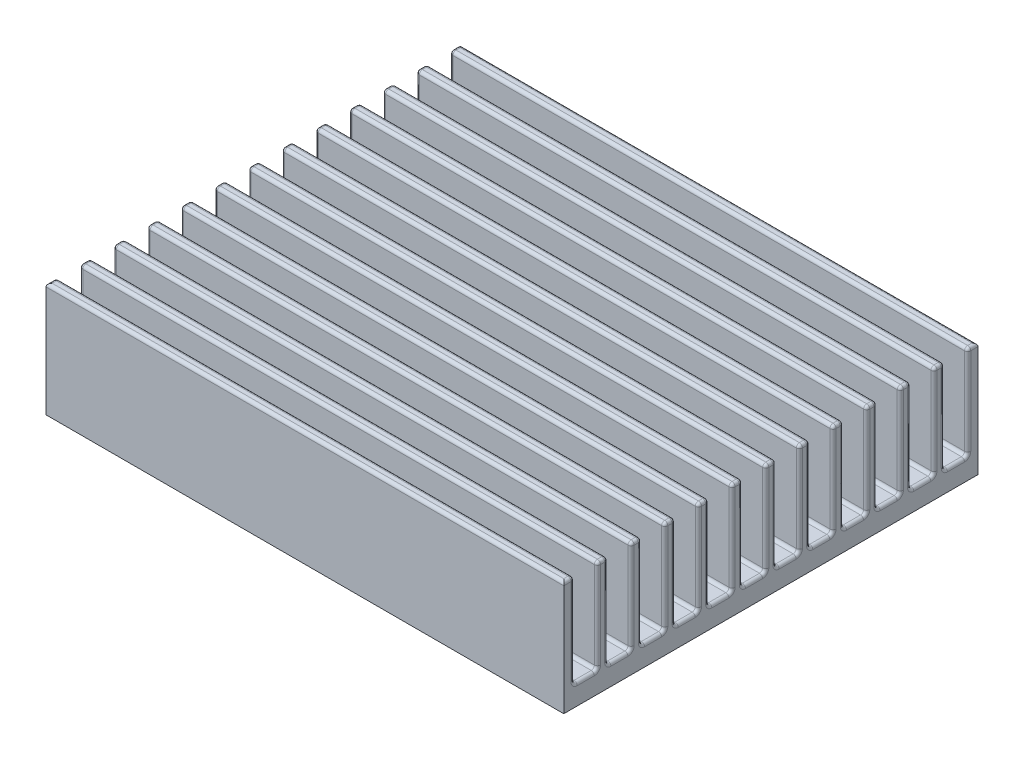
from build123d import *

# Parameters (mm, degrees)
SKETCH1_W           = 50
SKETCH1_H           = 40
BOSS_EXTRUDE1_DEPTH = 2
SKETCH2_W           = 1
SKETCH2_H           = 9
BOSS_EXTRUDE2_DEPTH = 50
FILLET1_R           = 0.3
SKETCH3_R           = 1.5
CUT_EXTRUDE1_DEPTH  = 2


with BuildPart() as part:
    # Sketch1 → Boss-Extrude1 (new body)
    with BuildSketch(Plane(origin=(0, 0, 0), x_dir=(1, 0, 0), z_dir=(0, 1, 0))):
        Rectangle(SKETCH1_W, SKETCH1_H)
    extrude(amount=BOSS_EXTRUDE1_DEPTH)

    # Sketch2 → Boss-Extrude2 (add)
    with BuildSketch(Plane(origin=(25, 0, 0), x_dir=(0, 0, -1), z_dir=(1, 0, 0))):
        with Locations((-19.5, 6.5)):
            Rectangle(SKETCH2_W, SKETCH2_H)
        with Locations((-16.25, 6.5)):
            Rectangle(SKETCH2_W, SKETCH2_H)
        with Locations((-13, 6.5)):
            Rectangle(SKETCH2_W, SKETCH2_H)
        with Locations((-9.75, 6.5)):
            Rectangle(SKETCH2_W, SKETCH2_H)
        with Locations((-6.5, 6.5)):
            Rectangle(SKETCH2_W, SKETCH2_H)
        with Locations((-3.25, 6.5)):
            Rectangle(SKETCH2_W, SKETCH2_H)
        with Locations((0, 6.5)):
            Rectangle(SKETCH2_W, SKETCH2_H)
        with Locations((3.25, 6.5)):
            Rectangle(SKETCH2_W, SKETCH2_H)
        with Locations((6.5, 6.5)):
            Rectangle(SKETCH2_W, SKETCH2_H)
        with Locations((9.75, 6.5)):
            Rectangle(SKETCH2_W, SKETCH2_H)
        with Locations((13, 6.5)):
            Rectangle(SKETCH2_W, SKETCH2_H)
        with Locations((16.25, 6.5)):
            Rectangle(SKETCH2_W, SKETCH2_H)
        with Locations((19.5, 6.5)):
            Rectangle(SKETCH2_W, SKETCH2_H)
    extrude(amount=-BOSS_EXTRUDE2_DEPTH)

    # Fillet1
    fillet1_edges = [part.edges().sort_by_distance(p)[0] for p in [
        (0, 11, -6),
        (0, 11, -7),
        (0, 2, -7),
        (0, 2, -6),
        (25, 11, -6.5),
        (25, 6.5, -6),
        (25, 6.5, -7),
        (-25, 11, -6.5),
        (-25, 6.5, -7),
        (-25, 6.5, -6),
        (-25, 2, -8.125),
        (25, 2, -11.375),
        (0, 11, -9.25),
        (0, 11, -10.25),
        (0, 2, -10.25),
        (0, 2, -9.25),
        (25, 11, -9.75),
        (25, 6.5, -9.25),
        (25, 6.5, -10.25),
        (-25, 11, -9.75),
        (-25, 6.5, -10.25),
        (-25, 6.5, -9.25),
        (-25, 2, -11.375),
        (25, 2, -14.625),
        (0, 11, -12.5),
        (0, 11, -13.5),
        (0, 2, -13.5),
        (0, 2, -12.5),
        (25, 11, -13),
        (25, 6.5, -12.5),
        (25, 6.5, -13.5),
        (-25, 11, -13),
        (-25, 6.5, -13.5),
        (-25, 6.5, -12.5),
        (-25, 2, -14.625),
        (25, 2, -17.875),
        (0, 11, -15.75),
        (0, 11, -16.75),
        (0, 2, -16.75),
        (0, 2, -15.75),
        (25, 11, -16.25),
        (25, 6.5, -15.75),
        (25, 6.5, -16.75),
        (-25, 11, -16.25),
        (-25, 6.5, -16.75),
        (-25, 6.5, -15.75),
        (25, 2, 17.875),
        (-25, 2, -17.875),
        (0, 11, -19),
        (0, 11, -20),
        (0, 2, -19),
        (25, 11, -19.5),
        (25, 6.5, -19),
        (-25, 11, -19.5),
        (-25, 6.5, -19),
        (0, 11, 20),
        (0, 11, 19),
        (0, 2, 19),
        (25, 11, 19.5),
        (25, 6.5, 19),
        (-25, 11, 19.5),
        (-25, 6.5, 19),
        (-25, 2, 17.875),
        (25, 2, 14.625),
        (0, 11, 16.75),
        (0, 11, 15.75),
        (0, 2, 15.75),
        (0, 2, 16.75),
        (25, 11, 16.25),
        (25, 6.5, 16.75),
        (25, 6.5, 15.75),
        (-25, 11, 16.25),
        (-25, 6.5, 15.75),
        (-25, 6.5, 16.75),
        (-25, 2, 14.625),
        (25, 2, 11.375),
        (0, 11, 13.5),
        (0, 11, 12.5),
        (0, 2, 12.5),
        (0, 2, 13.5),
        (25, 11, 13),
        (25, 6.5, 13.5),
        (25, 6.5, 12.5),
        (-25, 11, 13),
        (-25, 6.5, 12.5),
        (-25, 6.5, 13.5),
        (-25, 2, 11.375),
        (25, 2, 8.125),
        (0, 11, 10.25),
        (0, 11, 9.25),
        (0, 2, 9.25),
        (0, 2, 10.25),
        (25, 11, 9.75),
        (25, 6.5, 10.25),
        (25, 6.5, 9.25),
        (-25, 11, 9.75),
        (-25, 6.5, 9.25),
        (-25, 6.5, 10.25),
        (-25, 2, 8.125),
        (25, 2, 4.875),
        (0, 11, 7),
        (0, 11, 6),
        (0, 2, 6),
        (0, 2, 7),
        (25, 11, 6.5),
        (25, 6.5, 7),
        (25, 6.5, 6),
        (-25, 11, 6.5),
        (-25, 6.5, 6),
        (-25, 6.5, 7),
        (-25, 2, 4.875),
        (25, 2, 1.625),
        (0, 11, 3.75),
        (0, 11, 2.75),
        (0, 2, 2.75),
        (0, 2, 3.75),
        (25, 11, 3.25),
        (25, 6.5, 3.75),
        (25, 6.5, 2.75),
        (-25, 11, 3.25),
        (-25, 6.5, 2.75),
        (-25, 6.5, 3.75),
        (-25, 2, 1.625),
        (25, 2, -1.625),
        (0, 11, 0.5),
        (0, 11, -0.5),
        (0, 2, -0.5),
        (0, 2, 0.5),
        (25, 11, 0),
        (25, 6.5, 0.5),
        (25, 6.5, -0.5),
        (-25, 11, 0),
        (-25, 6.5, -0.5),
        (-25, 6.5, 0.5),
        (-25, 2, -1.625),
        (25, 2, -4.875),
        (0, 11, -2.75),
        (0, 11, -3.75),
        (0, 2, -3.75),
        (0, 2, -2.75),
        (25, 11, -3.25),
        (25, 6.5, -2.75),
        (25, 6.5, -3.75),
        (-25, 11, -3.25),
        (-25, 6.5, -3.75),
        (-25, 6.5, -2.75),
        (-25, 2, -4.875),
        (25, 2, -8.125),
    ]]
    fillet(fillet1_edges, radius=FILLET1_R)

    # Sketch3 → Cut-Extrude1 (cut)
    with BuildSketch(Plane.XZ):
        with Locations((-15, -7)):
            Circle(SKETCH3_R)
        with Locations((15, -7)):
            Circle(SKETCH3_R)
    extrude(amount=-CUT_EXTRUDE1_DEPTH, mode=Mode.SUBTRACT)


solid = part.part
